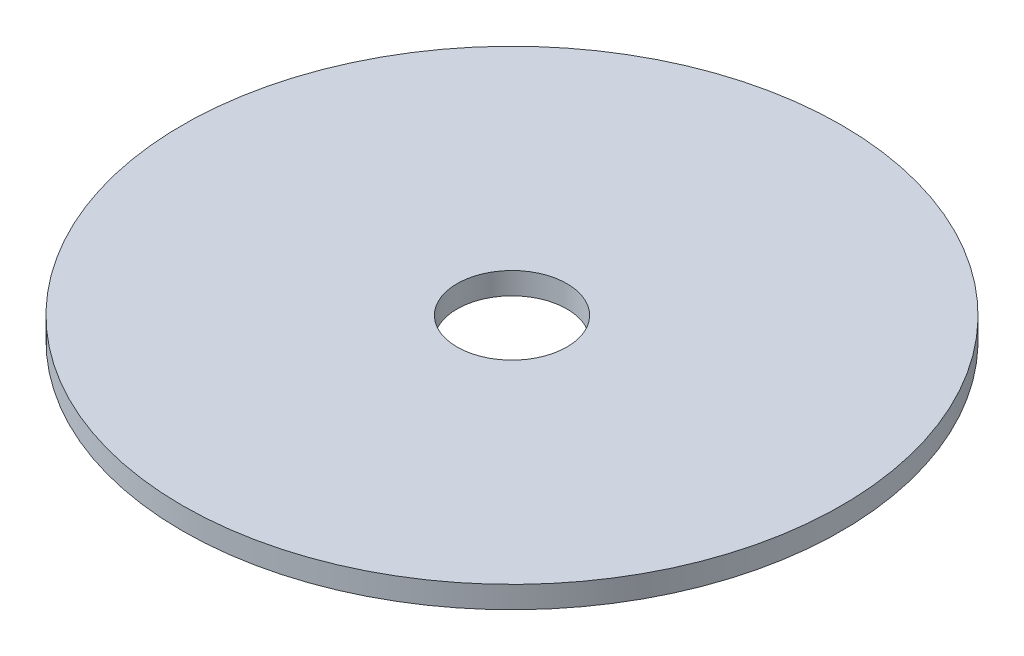
from build123d import *

# Parameters (mm, degrees)
SKETCH1_R           = 60
BOSS_EXTRUDE1_DEPTH = 4
SKETCH2_R           = 10
CUT_EXTRUDE1_DEPTH  = 10


with BuildPart() as part:
    # Sketch1 → Boss-Extrude1 (new body)
    with BuildSketch(Plane(origin=(0, 0, 0), x_dir=(1, 0, 0), z_dir=(0, 1, 0))):
        Circle(SKETCH1_R)
    extrude(amount=BOSS_EXTRUDE1_DEPTH)

    # Sketch2 → Cut-Extrude1 (cut)
    with BuildSketch(Plane(origin=(0, 4, 0), x_dir=(1, 0, 0), z_dir=(0, 1, 0))):
        Circle(SKETCH2_R)
    extrude(amount=-CUT_EXTRUDE1_DEPTH, mode=Mode.SUBTRACT)


solid = part.part
